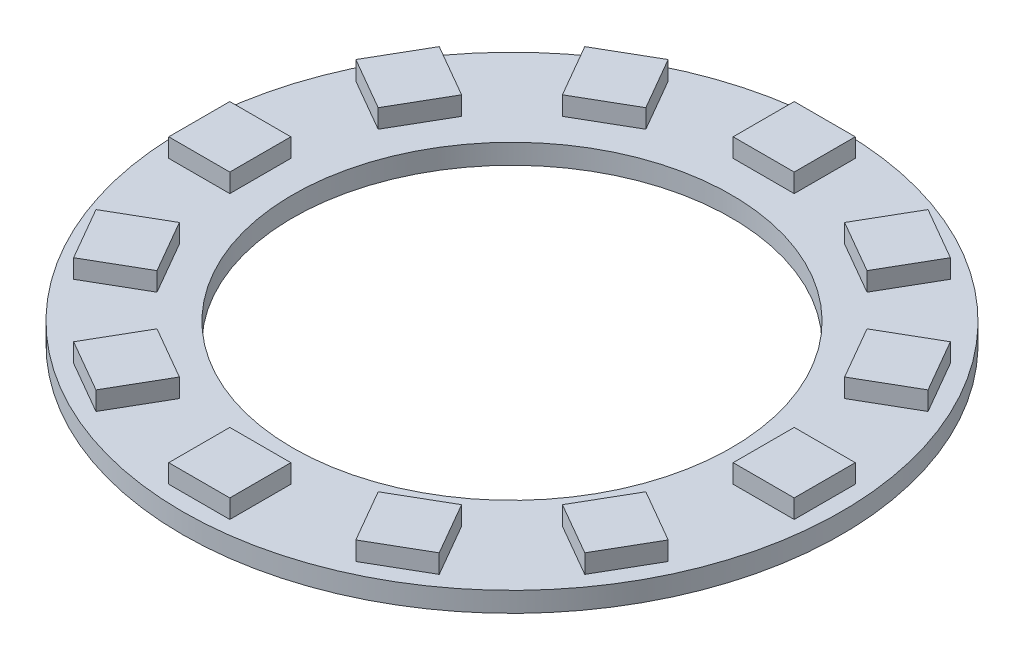
from build123d import *

# Parameters (mm, degrees)
SKETCH_1_R               = 26.45
SKETCH_1_R_2             = 17.6
EXTRUDE_1_DEPTH          = 1.6
SKETCH_2_W               = 4.9
SKETCH_2_H               = 4.9
EXTRUDE_2_DEPTH          = 1.5
PATTERN_CIRCULAR_1_COUNT = 12


with BuildPart() as part:
    # 草图1 → 凸台-拉伸1 (new body)
    with BuildSketch(Plane(origin=(0, 0, 0), x_dir=(1, 0, 0), z_dir=(0, 1, 0))):
        Circle(SKETCH_1_R)
        Circle(SKETCH_1_R_2, mode=Mode.SUBTRACT)
    extrude(amount=EXTRUDE_1_DEPTH)

    # 草图2 → 凸台-拉伸2 (add)
    with BuildSketch(Plane(origin=(0, 1.6, 0), x_dir=(1, 0, 0), z_dir=(0, 1, 0))):
        with Locations((-22.65, 0)):
            Rectangle(SKETCH_2_W, SKETCH_2_H)
    extrude_2 = extrude(amount=EXTRUDE_2_DEPTH)

    # 阵列(圆周)1: 凸台-拉伸2 ×12 about axis
    pattern_circular_1_axis = Axis((0, 0, 0), (0, 1, 0))
    for i in range(1, PATTERN_CIRCULAR_1_COUNT):
        add(extrude_2.rotate(pattern_circular_1_axis, i * 360 / PATTERN_CIRCULAR_1_COUNT))


solid = part.part
